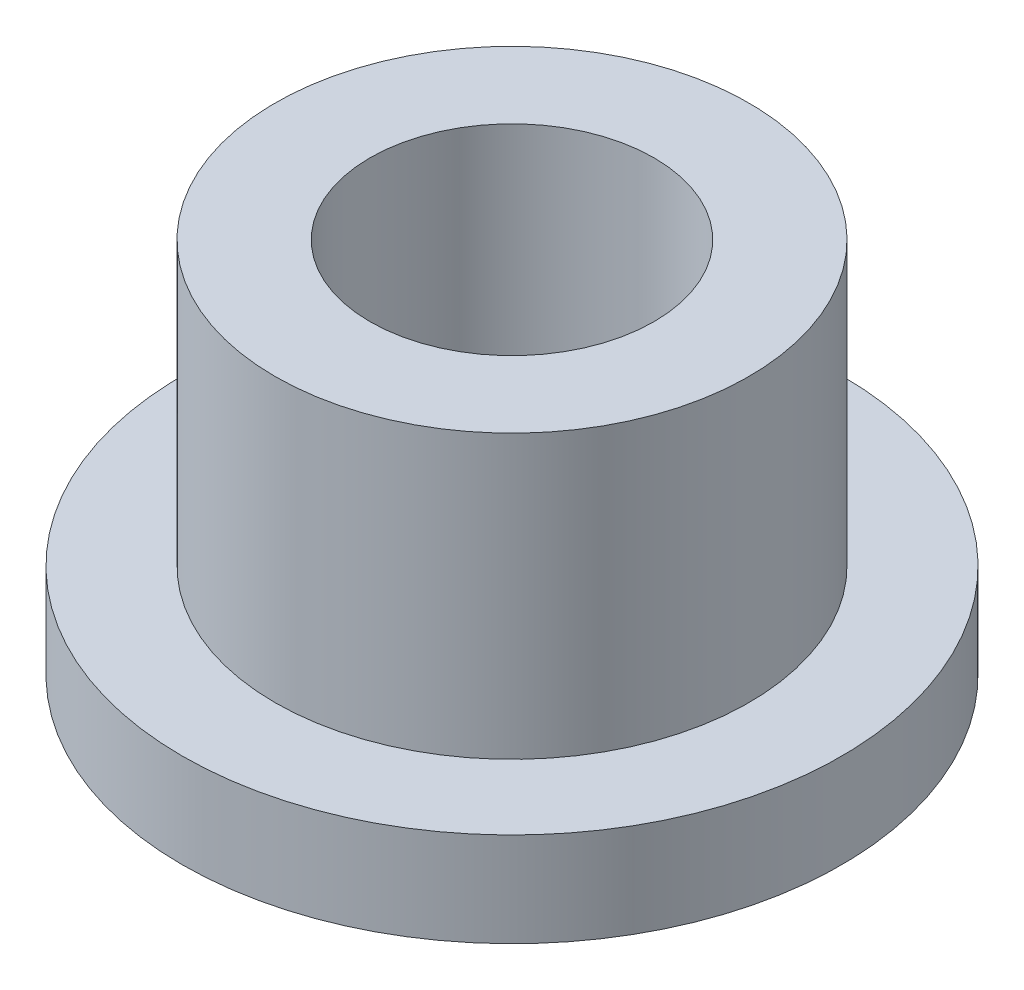
from build123d import *

# Parameters (mm, degrees)
SKETCH2_R           = 3.99415
SKETCH2_R_2         = 2.39395
BOSS_EXTRUDE1_DEPTH = 6.35
SKETCH3_R           = 5.55625
SKETCH3_R_2         = 3.99415
BOSS_EXTRUDE2_DEPTH = 1.5875


with BuildPart() as part:
    # Sketch2 → Boss-Extrude1 (new body)
    with BuildSketch(Plane(origin=(0, 0, 0), x_dir=(1, 0, 0), z_dir=(0, 1, 0))):
        Circle(SKETCH2_R)
        Circle(SKETCH2_R_2, mode=Mode.SUBTRACT)
    extrude(amount=BOSS_EXTRUDE1_DEPTH)

    # Sketch3 → Boss-Extrude2 (add)
    with BuildSketch(Plane(origin=(0, 0, 0), x_dir=(1, 0, 0), z_dir=(0, 1, 0))):
        Circle(SKETCH3_R)
        Circle(SKETCH3_R_2, mode=Mode.SUBTRACT)
    extrude(amount=BOSS_EXTRUDE2_DEPTH)


solid = part.part
